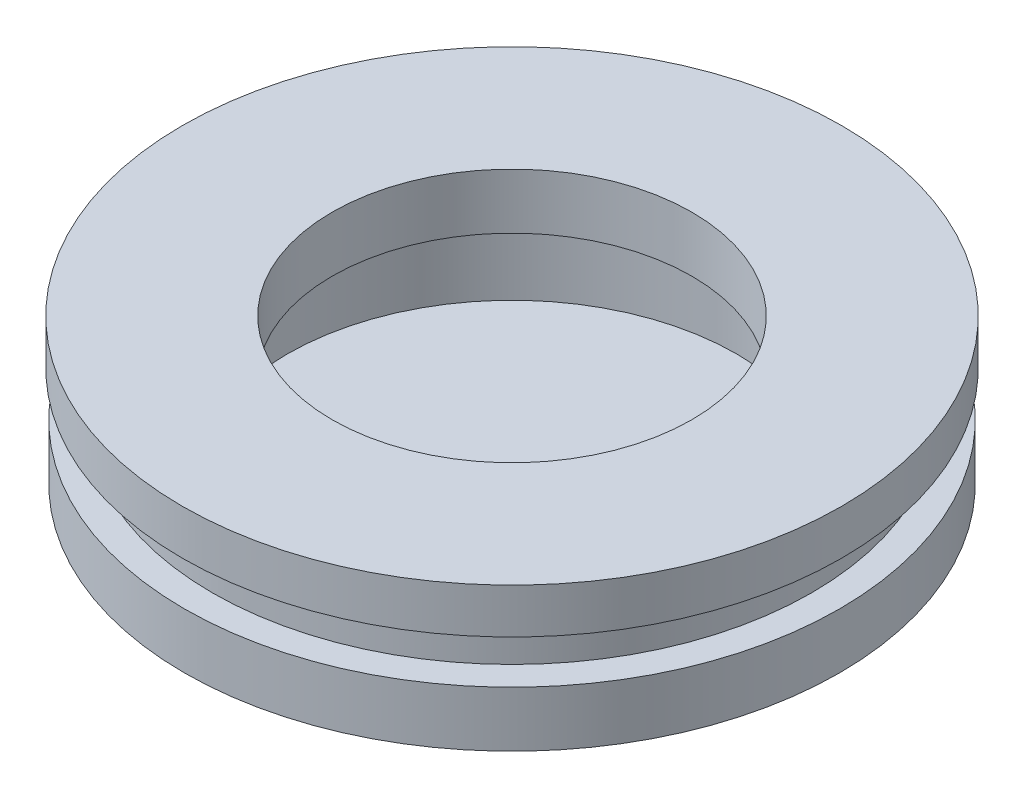
from build123d import *


with BuildPart() as part:
    # Sketch1 → Revolve1 (revolve)
    with BuildSketch(Plane.XY):
        Polygon((0, 0), (0, 8.828029189), (-11, 8.828029189), (-11, 7.328029189), (-10, 7.328029189), (-10, 5.828029189), (-10.929545371, 5.828029189), (-10.929545371, 3.978029189), align=None)
    revolve(axis=Axis((0, 0, 0), (0, 1, 0)))

    # Sketch2 → Cut-Revolve1 (revolve, cut)
    with BuildSketch(Plane.XY):
        Polygon((0, 3.978029189), (0, 9.978029189), (-6, 9.978029189), (-6, 6.978029189), (-7.5, 6.978029189), (-7.5, 3.978029189), align=None)
    revolve(axis=Axis((0, 3.978029189, 0), (0, 1, 0)), mode=Mode.SUBTRACT)


solid = part.part
